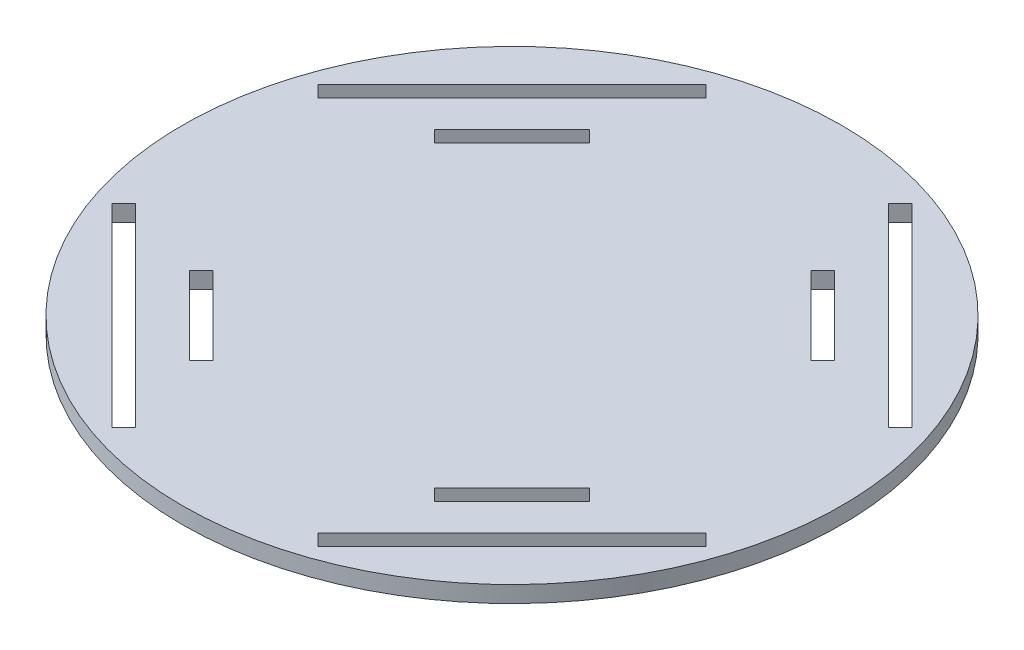
from build123d import *

# Parameters (mm, degrees)
SKETCH1_R           = 60
BOSS_EXTRUDE1_DEPTH = 1.5
CUT_EXTRUDE3_START  = -4
CUT_EXTRUDE3_DEPTH  = 5
CIRPATTERN1_COUNT   = 4
CUT_EXTRUDE4_DEPTH  = 4
CIRPATTERN2_COUNT   = 4


with BuildPart() as part:
    # Sketch1 → Boss-Extrude1 (new body, symmetric)
    with BuildSketch(Plane(origin=(0, 0, 0), x_dir=(1, 0, 0), z_dir=(0, 1, 0))):
        Circle(SKETCH1_R)
    extrude(amount=BOSS_EXTRUDE1_DEPTH, both=True)

    # Sketch4 → Cut-Extrude3 (cut)
    with BuildSketch(Plane(origin=(0, 1.5, 0), x_dir=(1, 0, 0), z_dir=(0, 1, 0)).offset(CUT_EXTRUDE3_START)):
        Polygon((16.617009358, 51.972348417), (51.972348417, 16.617009358), (54.093668761, 18.738329701), (18.738329701, 54.093668761), align=None)
    cut_extrude3 = extrude(amount=CUT_EXTRUDE3_DEPTH, mode=Mode.SUBTRACT)

    # CirPattern1: Cut-Extrude3 ×4 about axis
    cirpattern1_axis = Axis((0, 0, 0), (0, 1, 0))
    for i in range(1, CIRPATTERN1_COUNT):
        add(cut_extrude3.rotate(cirpattern1_axis, i * 360 / CIRPATTERN1_COUNT), mode=Mode.SUBTRACT)

    # Sketch5 → Cut-Extrude4 (cut, through all)
    with BuildSketch(Plane(origin=(0, 1.5, 0), x_dir=(1, 0, 0), z_dir=(0, 1, 0))):
        Polygon((22.273863607, 36.415999231), (36.415999231, 22.273863607), (34.294678888, 20.152543264), (20.152543264, 34.294678888), align=None)
    cut_extrude4 = extrude(amount=-CUT_EXTRUDE4_DEPTH, mode=Mode.SUBTRACT)

    # CirPattern2: Cut-Extrude4 ×4 about axis
    cirpattern2_axis = Axis((0, 0, 0), (0, 1, 0))
    for i in range(1, CIRPATTERN2_COUNT):
        add(cut_extrude4.rotate(cirpattern2_axis, i * 360 / CIRPATTERN2_COUNT), mode=Mode.SUBTRACT)


solid = part.part
